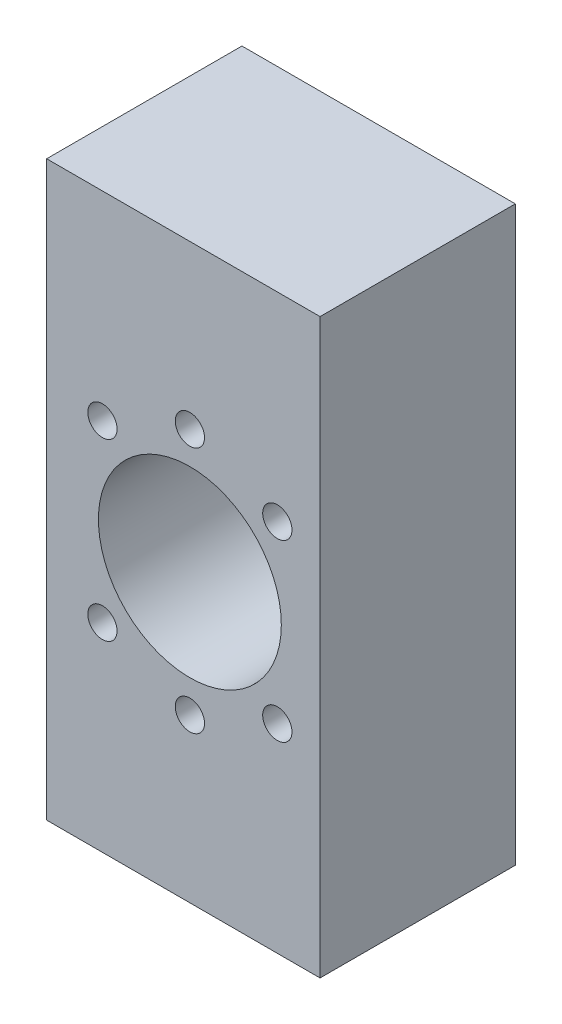
from build123d import *

# Parameters (mm, degrees)
EXTRUDE7_START     = 10
SKETCH1_R          = 2.25
SKETCH1_R_2        = 14.05
EXTRUDE7_DEPTH     = 30
CUT_EXTRUDE6_START = 2
SKETCH8_R          = 2.25
CUT_EXTRUDE6_DEPTH = 30


with BuildPart() as part:
    # Sketch1 → Extrude7 (new body)
    with BuildSketch(Plane.XY.offset(EXTRUDE7_START)):
        Polygon((20, 44), (-20, 44), (-22, 44), (-22, -44), (-20, -44), (20, -44), align=None)
        with Locations((-13.435028843, -13.435028843)):
            Circle(SKETCH1_R, mode=Mode.SUBTRACT)
        with Locations((0, -19)):
            Circle(SKETCH1_R, mode=Mode.SUBTRACT)
        with Locations((13.435028843, -13.435028843)):
            Circle(SKETCH1_R, mode=Mode.SUBTRACT)
        with Locations((-13.435028843, 13.435028843)):
            Circle(SKETCH1_R, mode=Mode.SUBTRACT)
        Circle(SKETCH1_R_2, mode=Mode.SUBTRACT)
        with Locations((0, 19)):
            Circle(SKETCH1_R, mode=Mode.SUBTRACT)
        with Locations((13.435028843, 13.435028843)):
            Circle(SKETCH1_R, mode=Mode.SUBTRACT)
        Polygon((20, 44), (-20, 44), (-22, 44), (-22, -44), (-20, -44), (20, -44), align=None)
        with Locations((-13.435028843, -13.435028843)):
            Circle(SKETCH1_R, mode=Mode.SUBTRACT)
        with Locations((0, -19)):
            Circle(SKETCH1_R, mode=Mode.SUBTRACT)
        with Locations((13.435028843, -13.435028843)):
            Circle(SKETCH1_R, mode=Mode.SUBTRACT)
        with Locations((-13.435028843, 13.435028843)):
            Circle(SKETCH1_R, mode=Mode.SUBTRACT)
        Circle(SKETCH1_R_2, mode=Mode.SUBTRACT)
        with Locations((0, 19)):
            Circle(SKETCH1_R, mode=Mode.SUBTRACT)
        with Locations((13.435028843, 13.435028843)):
            Circle(SKETCH1_R, mode=Mode.SUBTRACT)
        Polygon((20, 44), (-20, 44), (-22, 44), (-22, -44), (-20, -44), (20, -44), align=None)
        with Locations((-13.435028843, -13.435028843)):
            Circle(SKETCH1_R, mode=Mode.SUBTRACT)
        with Locations((0, -19)):
            Circle(SKETCH1_R, mode=Mode.SUBTRACT)
        with Locations((13.435028843, -13.435028843)):
            Circle(SKETCH1_R, mode=Mode.SUBTRACT)
        with Locations((-13.435028843, 13.435028843)):
            Circle(SKETCH1_R, mode=Mode.SUBTRACT)
        Circle(SKETCH1_R_2, mode=Mode.SUBTRACT)
        with Locations((0, 19)):
            Circle(SKETCH1_R, mode=Mode.SUBTRACT)
        with Locations((13.435028843, 13.435028843)):
            Circle(SKETCH1_R, mode=Mode.SUBTRACT)
    extrude(amount=EXTRUDE7_DEPTH)

    # Sketch8 → Cut-Extrude6 (cut)
    with BuildSketch(Plane.ZY.offset(20).offset(CUT_EXTRUDE6_START)):
        with Locations((17.5, 39)):
            Circle(SKETCH8_R)
        with Locations((32.5, 39)):
            Circle(SKETCH8_R)
        with Locations((17.5, -39)):
            Circle(SKETCH8_R)
        with Locations((32.5, -39)):
            Circle(SKETCH8_R)
        with Locations((17.5, 29)):
            Circle(SKETCH8_R)
        with Locations((32.5, 29)):
            Circle(SKETCH8_R)
        with Locations((17.5, -29)):
            Circle(SKETCH8_R)
        with Locations((32.5, -29)):
            Circle(SKETCH8_R)
    extrude(amount=-CUT_EXTRUDE6_DEPTH, mode=Mode.SUBTRACT)


solid = part.part
